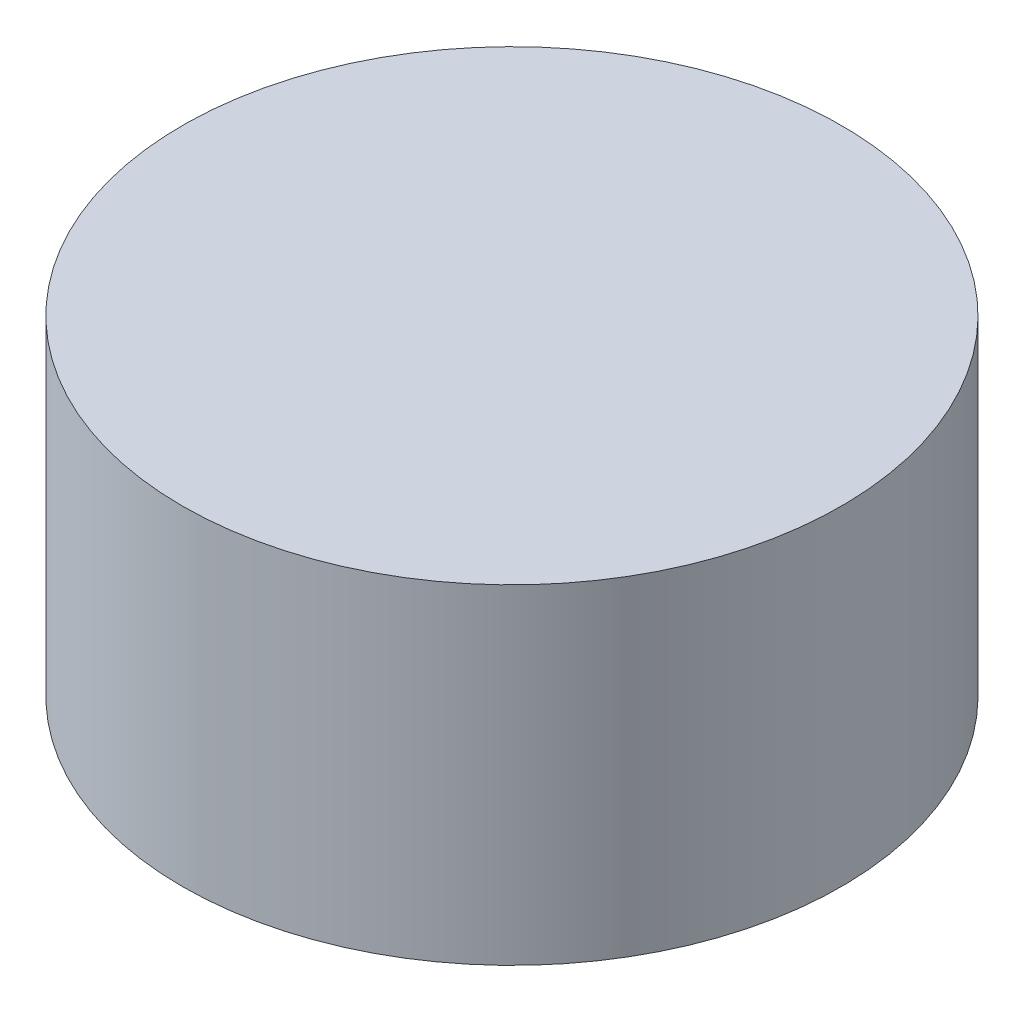
from build123d import *

# Parameters (mm, degrees)
SKETCH_1_R      = 3
EXTRUDE_1_DEPTH = 3


with BuildPart() as part:
    # 草图1 → 凸台-拉伸1 (new body)
    with BuildSketch(Plane(origin=(0, 0, 0), x_dir=(1, 0, 0), z_dir=(0, 1, 0))):
        Circle(SKETCH_1_R)
    extrude(amount=EXTRUDE_1_DEPTH)


solid = part.part
